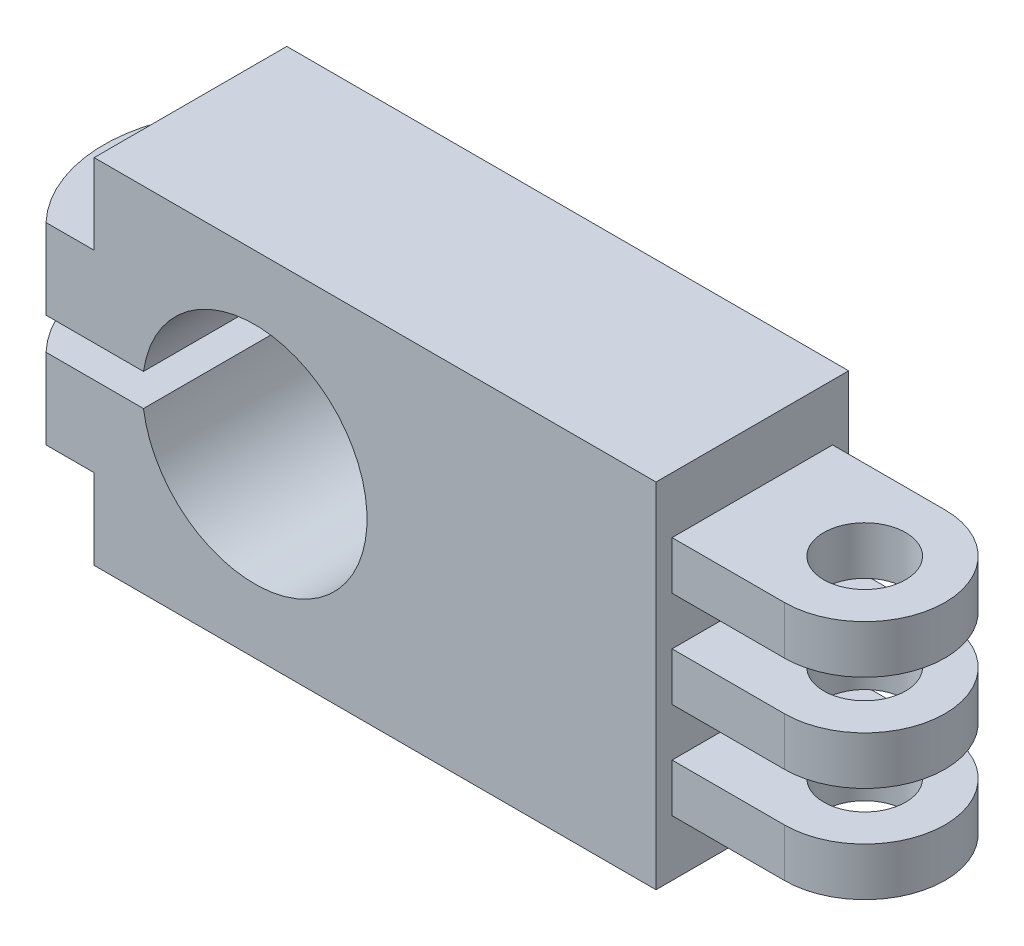
from build123d import *

# Parameters (mm, degrees)
EXTRUDE_1_DEPTH     = 12
SKETCH_2_R          = 2.55
CUT_EXTRUDE_1_DEPTH = 19
CUT_EXTRUDE_2_DEPTH = 19
SKETCH_4_R          = 1
CUT_EXTRUDE_3_DEPTH = 19
SKETCH_5_W          = 10
SKETCH_5_H          = 2
CUT_EXTRUDE_4_DEPTH = 19
SKETCH_6_R          = 7
CUT_EXTRUDE_5_DEPTH = 19
CUT_EXTRUDE_6_DEPTH = 19


with BuildPart() as part:
    # 草图1 → 凸台-拉伸1 (new body)
    with BuildSketch(Plane.XY):
        Polygon((0, 0), (35, 0), (35, -3.5), (47, -3.5), (47, -6.5), (35, -6.5), (35, -9.5), (47, -9.5), (47, -12.5), (35, -12.5), (35, -15.5), (47, -15.5), (47, -18.5), (35, -18.5), (35, -22), (0, -22), (0, -17), (-10, -17), (-10, -12), (0, -12), (0, -10), (-10, -10), (-10, -5), (0, -5), align=None)
    extrude(amount=EXTRUDE_1_DEPTH)

    # 草图2 → 切除-拉伸1 (cut)
    with BuildSketch(Plane(origin=(0, -3.5, 0), x_dir=(1, 0, 0), z_dir=(0, 1, 0))):
        with Locations((42, -6)):
            Circle(SKETCH_2_R)
    extrude(amount=-CUT_EXTRUDE_1_DEPTH, mode=Mode.SUBTRACT)

    # 草图3 → 切除-拉伸2 (cut)
    with BuildSketch(Plane(origin=(0, -3.5, 0), x_dir=(1, 0, 0), z_dir=(0, 1, 0))):
        with BuildLine():
            Line((42, -1), (35, -1))
            Line((35, -1), (35, 1.362905895))
            Line((35, 1.362905895), (53.328864927, 1.362905895))
            Line((53.328864927, 1.362905895), (53.328864927, -14.813237877))
            Line((53.328864927, -14.813237877), (35, -14.813237877))
            Line((35, -14.813237877), (35, -11))
            Line((35, -11), (42, -11))
            ThreePointArc((42, -11), (47, -6), (42, -1))
        make_face()
    extrude(amount=-CUT_EXTRUDE_2_DEPTH, mode=Mode.SUBTRACT)

    # 草图4 → 切除-拉伸3 (cut)
    with BuildSketch(Plane.XZ.offset(17)):
        with Locations((-2.5, 6)):
            Circle(SKETCH_4_R)
    extrude(amount=-CUT_EXTRUDE_3_DEPTH, mode=Mode.SUBTRACT)

    # 草图5 → 切除-拉伸4 (cut)
    with BuildSketch(Plane.XY.offset(12)):
        with Locations((5, -11)):
            Rectangle(SKETCH_5_W, SKETCH_5_H)
    extrude(amount=-CUT_EXTRUDE_4_DEPTH, mode=Mode.SUBTRACT)

    # 草图6 → 切除-拉伸5 (cut)
    with BuildSketch(Plane.XY.offset(12)):
        with Locations((10, -11)):
            Circle(SKETCH_6_R)
    extrude(amount=-CUT_EXTRUDE_5_DEPTH, mode=Mode.SUBTRACT)

    # 草图7 → 切除-拉伸6 (cut)
    with BuildSketch(Plane(origin=(0, -5, 0), x_dir=(1, 0, 0), z_dir=(0, 1, 0))):
        with BuildLine():
            Line((-3, -12), (-3, -16.245470045))
            Line((-3, -16.245470045), (-15.241663488, -16.245470045))
            Line((-15.241663488, -16.245470045), (-15.241663488, 3.326156632))
            Line((-15.241663488, 3.326156632), (-3, 3.326156632))
            Line((-3, 3.326156632), (-3, 0))
            ThreePointArc((-3, 0), (-5.395390723, -6), (-3, -12))
        make_face()
    extrude(amount=-CUT_EXTRUDE_6_DEPTH, mode=Mode.SUBTRACT)


solid = part.part
